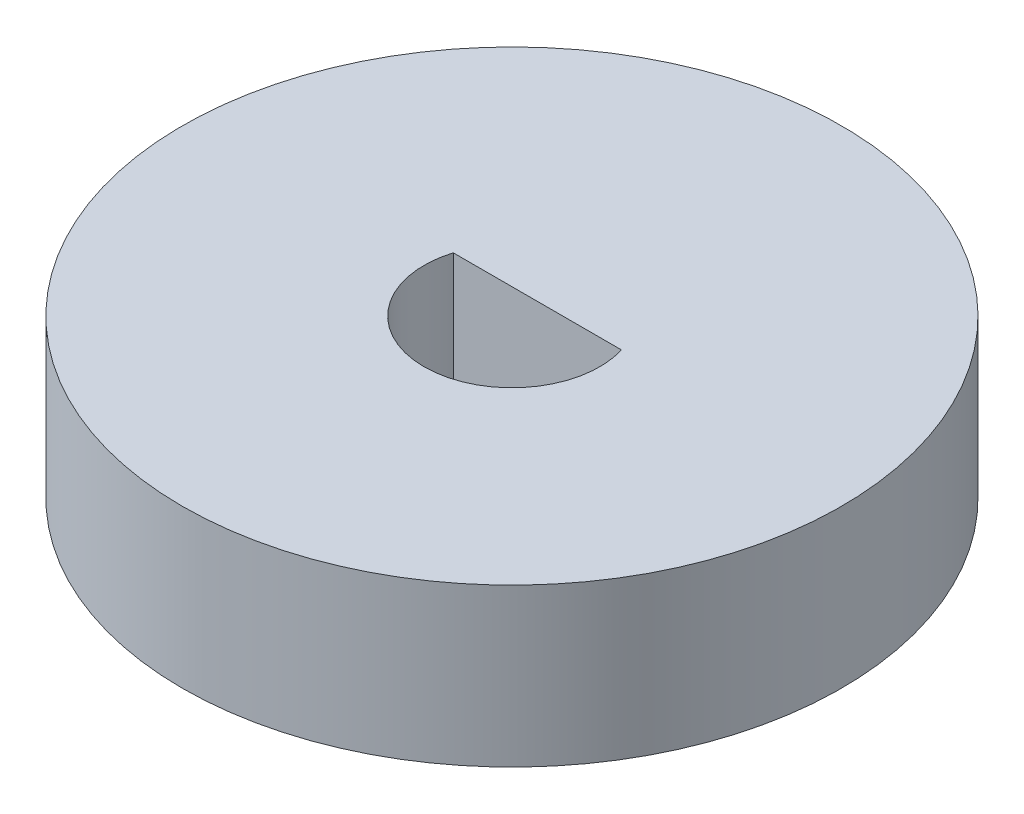
from build123d import *

# Parameters (mm, degrees)
SKETCH1_R           = 11.25
BOSS_EXTRUDE1_DEPTH = 5.38
SKETCH2_R           = 3
CUT_EXTRUDE1_DEPTH  = 5.38
SKETCH3_W           = 5.871522131
SKETCH3_H           = 2.131460622
BOSS_EXTRUDE2_DEPTH = 5.38


with BuildPart() as part:
    # Sketch1 → Boss-Extrude1 (new body)
    with BuildSketch(Plane(origin=(0, 0, 0), x_dir=(1, 0, 0), z_dir=(0, 1, 0))):
        Circle(SKETCH1_R)
    extrude(amount=BOSS_EXTRUDE1_DEPTH)

    # Sketch2 → Cut-Extrude1 (cut)
    with BuildSketch(Plane(origin=(0, 5.38, 0), x_dir=(1, 0, 0), z_dir=(0, 1, 0))):
        Circle(SKETCH2_R)
    extrude(amount=-CUT_EXTRUDE1_DEPTH, mode=Mode.SUBTRACT)

    # Sketch3 → Boss-Extrude2 (add)
    with BuildSketch(Plane(origin=(0, 5.38, 0), x_dir=(1, 0, 0), z_dir=(0, 1, 0))):
        with Locations((-0.064238934, 1.934269689)):
            Rectangle(SKETCH3_W, SKETCH3_H)
    extrude(amount=-BOSS_EXTRUDE2_DEPTH)


solid = part.part
